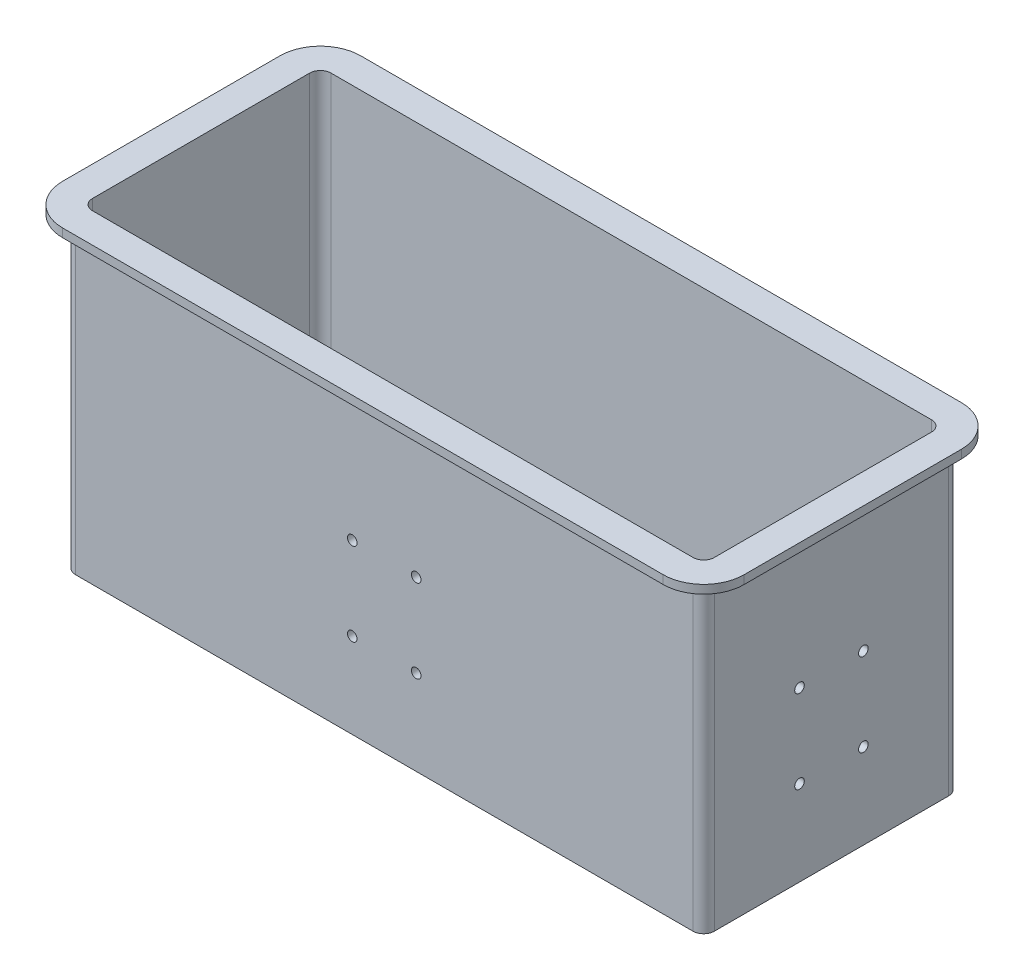
from build123d import *

# Parameters (mm, degrees)
SKETCH1_W           = 300
SKETCH1_H           = 120
BOSS_EXTRUDE1_DEPTH = 4
SKETCH2_W           = 300
SKETCH2_H           = 120
SKETCH2_W_2         = 292
SKETCH2_H_2         = 112
BOSS_EXTRUDE2_DEPTH = 140
FILLET1_R           = 5
BOSS_EXTRUDE3_DEPTH = 4
FILLET2_R           = 2
CUT_EXTRUDE1_REACH  = 312
SKETCH4_R           = 2.25
CUT_EXTRUDE2_REACH  = 132
SKETCH5_R           = 2.25


with BuildPart() as part:
    # Sketch1 → Boss-Extrude1 (new body)
    with BuildSketch(Plane(origin=(0, 0, 0), x_dir=(1, 0, 0), z_dir=(0, 1, 0))):
        Rectangle(SKETCH1_W, SKETCH1_H)
    extrude(amount=BOSS_EXTRUDE1_DEPTH)

    # Sketch2 → Boss-Extrude2 (add)
    with BuildSketch(Plane(origin=(0, 4, 0), x_dir=(1, 0, 0), z_dir=(0, 1, 0))):
        Rectangle(SKETCH2_W, SKETCH2_H)
        Rectangle(SKETCH2_W_2, SKETCH2_H_2, mode=Mode.SUBTRACT)
    extrude(amount=BOSS_EXTRUDE2_DEPTH)

    # Fillet1
    fillet1_edges = [part.edges().sort_by_distance(p)[0] for p in [
        (-146, 74, 56),
        (146, 74, 56),
        (146, 74, -56),
        (-146, 74, -56),
        (-150, 72, -60),
        (150, 72, -60),
        (150, 72, 60),
        (-150, 72, 60),
    ]]
    fillet(fillet1_edges, radius=FILLET1_R)

    # Sketch3 → Boss-Extrude3 (add)
    with BuildSketch(Plane(origin=(0, 144, 0), x_dir=(1, 0, 0), z_dir=(0, 1, 0))):
        with BuildLine():
            Line((-141, 70), (141, 70))
            ThreePointArc((141, 70), (154.435028843, 64.435028843), (160, 51))
            Line((160, 51), (160, -51))
            ThreePointArc((160, -51), (154.435028843, -64.435028843), (141, -70))
            Line((141, -70), (-141, -70))
            ThreePointArc((-141, -70), (-154.435028843, -64.435028843), (-160, -51))
            Line((-160, -51), (-160, 51))
            ThreePointArc((-160, 51), (-154.435028843, 64.435028843), (-141, 70))
        make_face()
        with BuildLine():
            Line((-141, 56), (141, 56))
            ThreePointArc((141, 56), (144.535533906, 54.535533906), (146, 51))
            Line((146, 51), (146, -51))
            ThreePointArc((146, -51), (144.535533906, -54.535533906), (141, -56))
            Line((141, -56), (-141, -56))
            ThreePointArc((-141, -56), (-144.535533906, -54.535533906), (-146, -51))
            Line((-146, -51), (-146, 51))
            ThreePointArc((-146, 51), (-144.535533906, 54.535533906), (-141, 56))
        make_face(mode=Mode.SUBTRACT)
    extrude(amount=BOSS_EXTRUDE3_DEPTH)

    # Fillet2
    fillet2_edges = [part.edges().sort_by_distance(p)[0] for p in [
        (0, 144, 60),
        (-150, 144, 0),
        (150, 144, 0),
        (0, 144, -60),
        (-148.535533906, 144, -58.535533906),
        (148.535533906, 144, -58.535533906),
        (148.535533906, 144, 58.535533906),
        (-148.535533906, 144, 58.535533906),
    ]]
    fillet(fillet2_edges, radius=FILLET2_R)

    # Sketch4 → Cut-Extrude1 (cut, up to next)
    with BuildSketch(Plane(origin=(150, 0, 0), x_dir=(0, 0, -1), z_dir=(1, 0, 0)), mode=Mode.PRIVATE) as cut_extrude1_sk1:
        with Locations((-15, 79)):
            Circle(SKETCH4_R)
    cut_extrude1_tool1 = extrude(cut_extrude1_sk1.sketch, amount=-CUT_EXTRUDE1_REACH, mode=Mode.PRIVATE) & part.part
    add(cut_extrude1_tool1.solids().sort_by_distance((150, 79, 15))[0], mode=Mode.SUBTRACT)
    # Sketch4 → Cut-Extrude1 (cut, up to next)
    with BuildSketch(Plane(origin=(150, 0, 0), x_dir=(0, 0, -1), z_dir=(1, 0, 0)), mode=Mode.PRIVATE) as cut_extrude1_sk2:
        with Locations((15, 79)):
            Circle(SKETCH4_R)
    cut_extrude1_tool2 = extrude(cut_extrude1_sk2.sketch, amount=-CUT_EXTRUDE1_REACH, mode=Mode.PRIVATE) & part.part
    add(cut_extrude1_tool2.solids().sort_by_distance((150, 79, -15))[0], mode=Mode.SUBTRACT)
    # Sketch4 → Cut-Extrude1 (cut, up to next)
    with BuildSketch(Plane(origin=(150, 0, 0), x_dir=(0, 0, -1), z_dir=(1, 0, 0)), mode=Mode.PRIVATE) as cut_extrude1_sk3:
        with Locations((15, 40)):
            Circle(SKETCH4_R)
    cut_extrude1_tool3 = extrude(cut_extrude1_sk3.sketch, amount=-CUT_EXTRUDE1_REACH, mode=Mode.PRIVATE) & part.part
    add(cut_extrude1_tool3.solids().sort_by_distance((150, 40, -15))[0], mode=Mode.SUBTRACT)
    # Sketch4 → Cut-Extrude1 (cut, up to next)
    with BuildSketch(Plane(origin=(150, 0, 0), x_dir=(0, 0, -1), z_dir=(1, 0, 0)), mode=Mode.PRIVATE) as cut_extrude1_sk4:
        with Locations((-15, 40)):
            Circle(SKETCH4_R)
    cut_extrude1_tool4 = extrude(cut_extrude1_sk4.sketch, amount=-CUT_EXTRUDE1_REACH, mode=Mode.PRIVATE) & part.part
    add(cut_extrude1_tool4.solids().sort_by_distance((150, 40, 15))[0], mode=Mode.SUBTRACT)

    # Sketch5 → Cut-Extrude2 (cut, up to next)
    with BuildSketch(Plane.XY.offset(60), mode=Mode.PRIVATE) as cut_extrude2_sk1:
        with Locations((15, 79)):
            Circle(SKETCH5_R)
    cut_extrude2_tool1 = extrude(cut_extrude2_sk1.sketch, amount=-CUT_EXTRUDE2_REACH, mode=Mode.PRIVATE) & part.part
    add(cut_extrude2_tool1.solids().sort_by_distance((15, 79, 60))[0], mode=Mode.SUBTRACT)
    # Sketch5 → Cut-Extrude2 (cut, up to next)
    with BuildSketch(Plane.XY.offset(60), mode=Mode.PRIVATE) as cut_extrude2_sk2:
        with Locations((-15, 79)):
            Circle(SKETCH5_R)
    cut_extrude2_tool2 = extrude(cut_extrude2_sk2.sketch, amount=-CUT_EXTRUDE2_REACH, mode=Mode.PRIVATE) & part.part
    add(cut_extrude2_tool2.solids().sort_by_distance((-15, 79, 60))[0], mode=Mode.SUBTRACT)
    # Sketch5 → Cut-Extrude2 (cut, up to next)
    with BuildSketch(Plane.XY.offset(60), mode=Mode.PRIVATE) as cut_extrude2_sk3:
        with Locations((-15, 40)):
            Circle(SKETCH5_R)
    cut_extrude2_tool3 = extrude(cut_extrude2_sk3.sketch, amount=-CUT_EXTRUDE2_REACH, mode=Mode.PRIVATE) & part.part
    add(cut_extrude2_tool3.solids().sort_by_distance((-15, 40, 60))[0], mode=Mode.SUBTRACT)
    # Sketch5 → Cut-Extrude2 (cut, up to next)
    with BuildSketch(Plane.XY.offset(60), mode=Mode.PRIVATE) as cut_extrude2_sk4:
        with Locations((15, 40)):
            Circle(SKETCH5_R)
    cut_extrude2_tool4 = extrude(cut_extrude2_sk4.sketch, amount=-CUT_EXTRUDE2_REACH, mode=Mode.PRIVATE) & part.part
    add(cut_extrude2_tool4.solids().sort_by_distance((15, 40, 60))[0], mode=Mode.SUBTRACT)


solid = part.part
